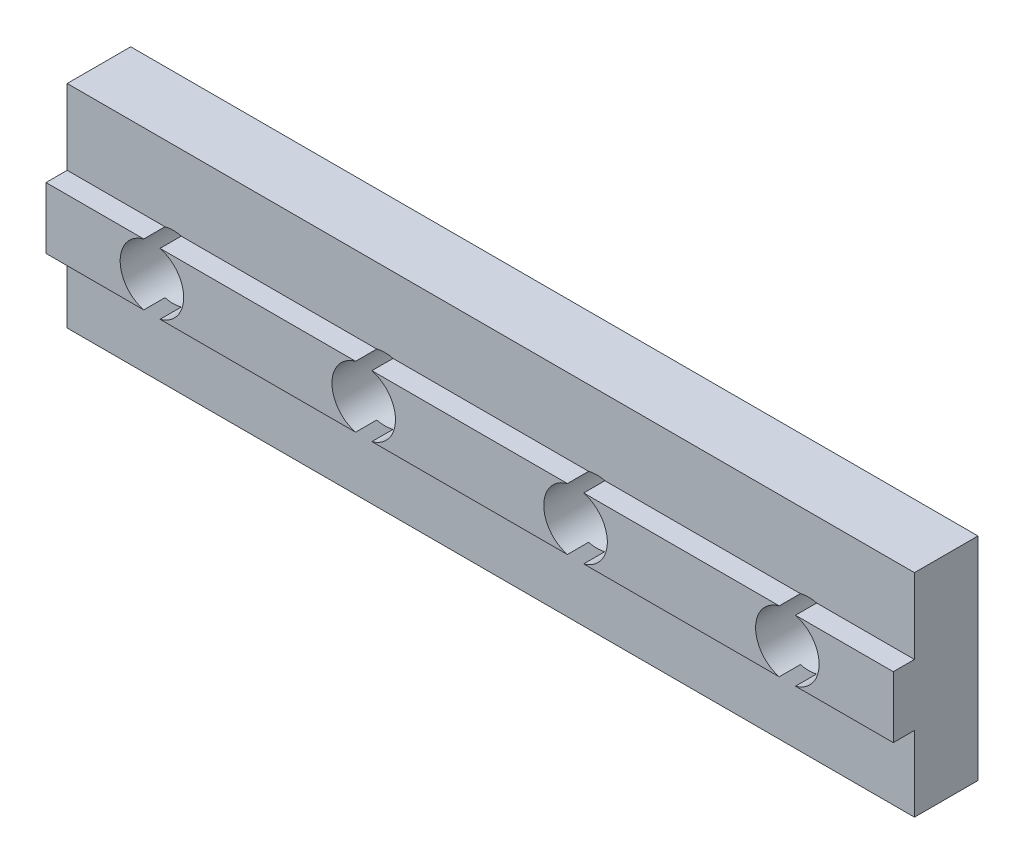
from build123d import *

# Parameters (mm, degrees)
ESQUISSE1_W                = 40
ESQUISSE1_H                = 10
BOSS_EXTRU_1_DEPTH         = 3
ESQUISSE2_W                = 40
ESQUISSE2_H                = 2.9
BOSS_EXTRU_2_DEPTH         = 1
ESQUISSE3_R                = 1.5
ENL_V_MAT_EXTRU_1_DEPTH    = 5
R_P_TITION_LIN_AIRE1_COUNT = 4
R_P_TITION_LIN_AIRE1_PITCH = 10


with BuildPart() as part:
    # Esquisse1 → Boss.-Extru.1 (new body)
    with BuildSketch(Plane.XY):
        with Locations((20, 5)):
            Rectangle(ESQUISSE1_W, ESQUISSE1_H)
    extrude(amount=BOSS_EXTRU_1_DEPTH)

    # Esquisse2 → Boss.-Extru.2 (add)
    with BuildSketch(Plane.XY.offset(3)):
        with Locations((20, 5)):
            Rectangle(ESQUISSE2_W, ESQUISSE2_H)
    extrude(amount=BOSS_EXTRU_2_DEPTH)

    # Esquisse3 → Enlèv. mat.-Extru.1 (cut, through all)
    with BuildSketch(Plane(origin=(0, 0, 0), x_dir=(-1, 0, 0), z_dir=(0, 0, -1))):
        with Locations((-35, 5)):
            Circle(ESQUISSE3_R)
    enl_v_mat_extru_1 = extrude(amount=-ENL_V_MAT_EXTRU_1_DEPTH, mode=Mode.SUBTRACT)

    # Répétition linéaire1: Enlèv. mat.-Extru.1 ×4
    with Locations(*[(-i * R_P_TITION_LIN_AIRE1_PITCH, 0, 0) for i in range(1, R_P_TITION_LIN_AIRE1_COUNT)]):
        add(enl_v_mat_extru_1, mode=Mode.SUBTRACT)


solid = part.part
